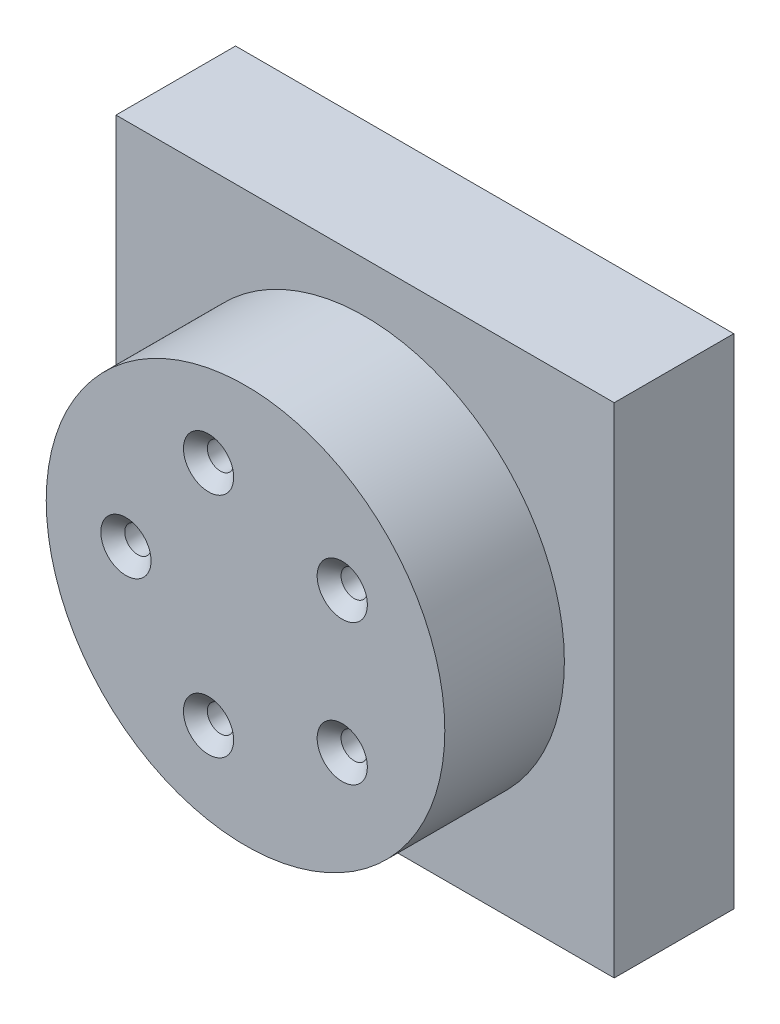
from build123d import *

# Parameters (mm, degrees)
SKETCH1_W                                       = 125
SKETCH1_H                                       = 125
BOSS_EXTRUDE1_DEPTH                             = 30
SKETCH1_3_R                                     = 50
BOSS_EXTRUDE2_DEPTH                             = 30
CSK_FOR_M6_FLAT_HEAD_MACHINE_SCREW1_D           = 6.6
CSK_FOR_M6_FLAT_HEAD_MACHINE_SCREW1_CSINK_D     = 12.6
CSK_FOR_M6_FLAT_HEAD_MACHINE_SCREW1_CSINK_ANGLE = 90
CIRPATTERN1_COUNT                               = 5


with BuildPart() as part:
    # Sketch1 → Boss-Extrude1 (new body)
    with BuildSketch(Plane.XY):
        Rectangle(SKETCH1_W, SKETCH1_H)
    extrude(amount=-BOSS_EXTRUDE1_DEPTH)

    # Sketch1_3 → Boss-Extrude2 (add)
    with BuildSketch(Plane.XY):
        Circle(SKETCH1_3_R)
    extrude(amount=BOSS_EXTRUDE2_DEPTH)

    # CSK for M6 Flat Head Machine Screw1 (through all)
    with Locations(Plane.XY.offset(30)):
        with Locations((-30, 0)):
            csk_for_m6_flat_head_machine_screw1 = CounterSinkHole(CSK_FOR_M6_FLAT_HEAD_MACHINE_SCREW1_D / 2, CSK_FOR_M6_FLAT_HEAD_MACHINE_SCREW1_CSINK_D / 2, counter_sink_angle=CSK_FOR_M6_FLAT_HEAD_MACHINE_SCREW1_CSINK_ANGLE)

    # CirPattern1: CSK for M6 Flat Head Machine Screw1 ×5 about axis
    cirpattern1_axis = Axis((0, 0, 0), (0, 0, 1))
    for i in range(1, CIRPATTERN1_COUNT):
        add(csk_for_m6_flat_head_machine_screw1.rotate(cirpattern1_axis, i * 360 / CIRPATTERN1_COUNT), mode=Mode.SUBTRACT)


solid = part.part
